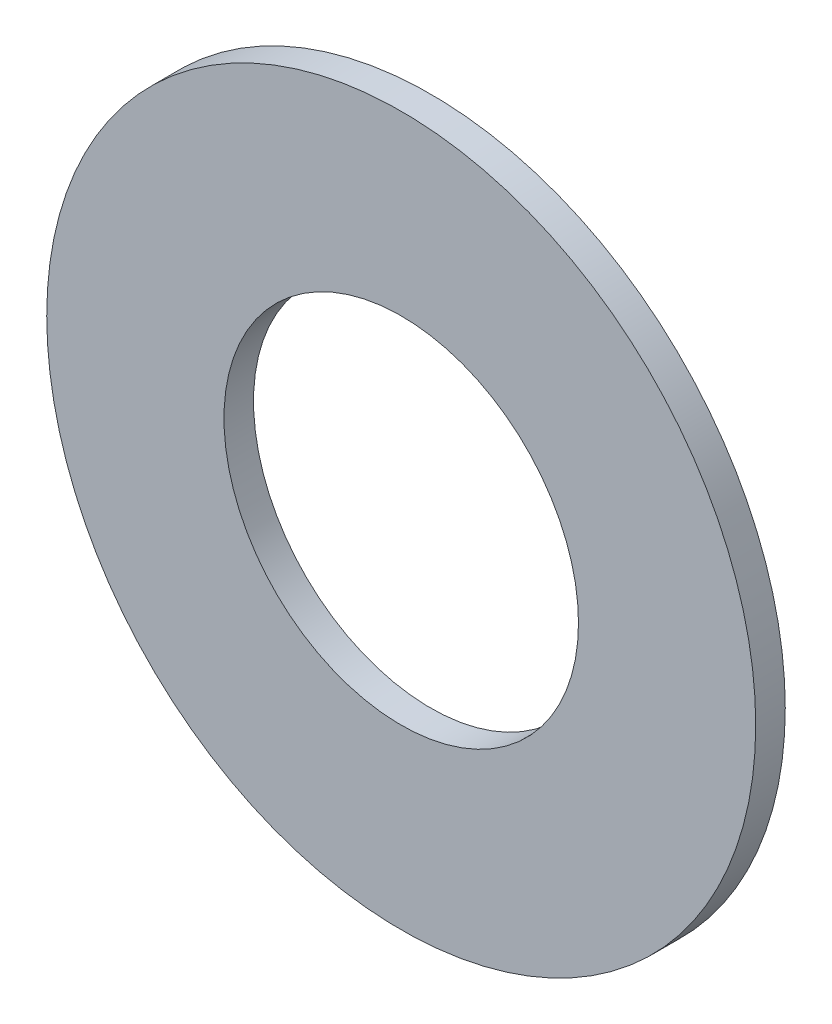
from build123d import *

# Parameters (mm, degrees)
SKETCH1_R           = 9.525
SKETCH1_R_2         = 4.7625
BOSS_EXTRUDE1_DEPTH = 0.79375


with BuildPart() as part:
    # Sketch1 → Boss-Extrude1 (new body)
    with BuildSketch(Plane.XY):
        Circle(SKETCH1_R)
        Circle(SKETCH1_R_2, mode=Mode.SUBTRACT)
    extrude(amount=BOSS_EXTRUDE1_DEPTH)


solid = part.part
